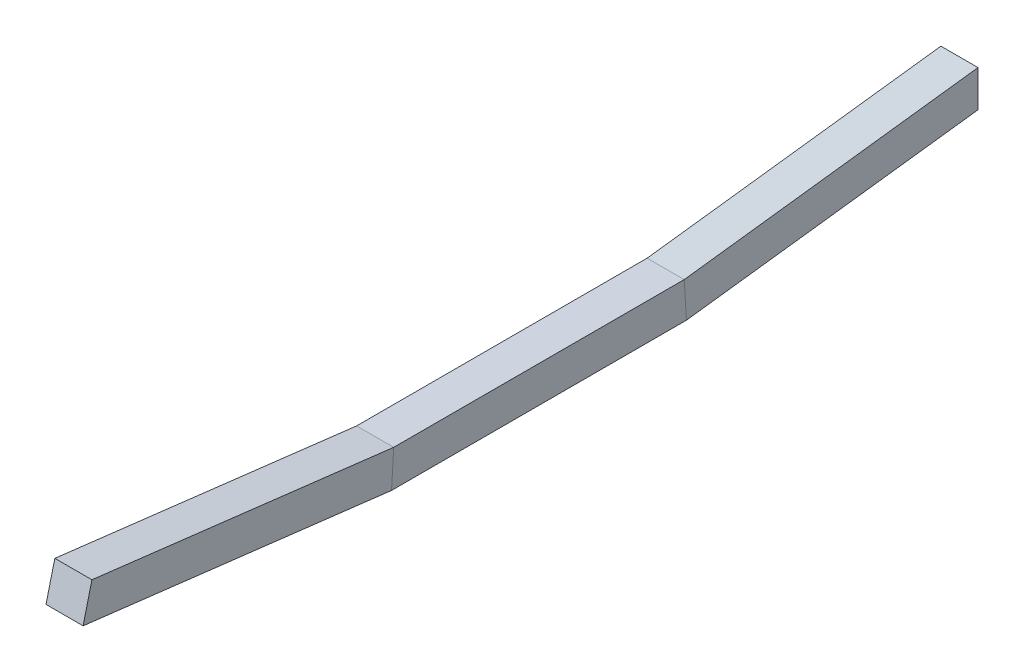
from build123d import *


with BuildPart() as part:
    # Sweep1: sweep along a curve in space
    with BuildLine() as sweep1_path:
        Line((409.121226164, 1758.017106037, 1349.85455637), (409.121226164, 1783.417106037, 1146.65455637))
        Line((409.121226164, 1758.017106037, 1349.85455637), (409.121226164, 1758.017106037, 1553.05455637))
        Line((409.121226164, 1758.017106037, 1553.05455637), (409.121226164, 1783.417106037, 1764.897256503))
    # 3DSketch2 → Sweep1 (sweep)
    with BuildSketch(Plane(origin=(396.244700962, 1770.717106037, 1146.65455637), x_dir=(0.7119701649816974, 0.7022097152389267, -7.366387974552788e-14), z_dir=(0, 0, -1))):
        Polygon((0, 0), (18.335403545, 18.084042191), (36.171530312, 0), (17.836126767, -18.084042191), align=None)
    sweep(path=sweep1_path.line, transition=Transition.RIGHT)


solid = part.part
